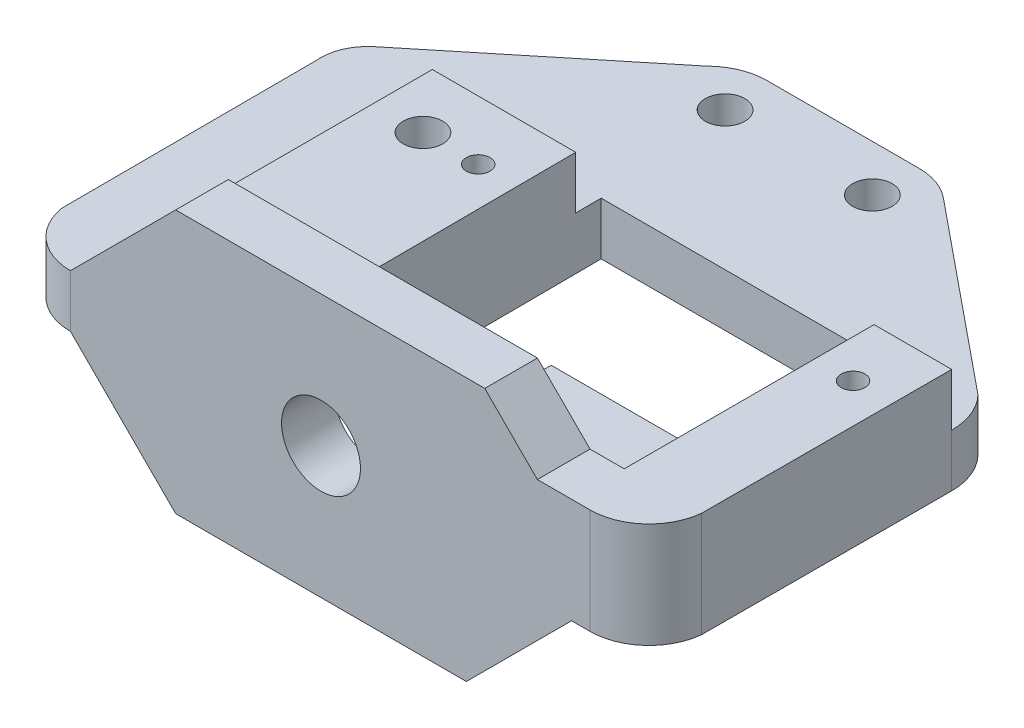
from build123d import *

# Parameters (mm, degrees)
CROQUIS1_R              = 1.500000078
CROQUIS1_R_2            = 0.899999978
CROQUIS1_R_3            = 0.899999104
CROQUIS1_R_4            = 1.499997939
CROQUIS1_R_5            = 1.500000378
SALIENTE_EXTRUIR1_DEPTH = 4
CROQUIS2_R              = 1.500000078
CROQUIS2_R_2            = 0.899999978
CROQUIS2_R_3            = 0.899999104
SALIENTE_EXTRUIR2_DEPTH = 4
CROQUIS3_W              = 35.500002289
CROQUIS3_H              = 4.004000187
SALIENTE_EXTRUIR3_DEPTH = 4
CROQUIS4_W              = 38.100002289
CROQUIS4_H              = 4.004000187
SALIENTE_EXTRUIR4_DEPTH = 8
CROQUIS5_R              = 3
CORTAR_EXTRUIR1_DEPTH   = 8


with BuildPart() as part:
    # Croquis1 → Saliente-Extruir1 (new body)
    with BuildSketch(Plane(origin=(0, 0, 0), x_dir=(1, 0, 0), z_dir=(0, 1, 0))):
        with BuildLine():
            Line((-19.24526482, -19.128405422), (20.25473518, -19.128405422))
            ThreePointArc((20.25473518, -19.128405422), (23.250093999, -17.982284574), (24.715306469, -15.12940535))
            Line((24.715306469, -15.12940535), (24.75473518, 3.871594578))
            ThreePointArc((24.75473518, 3.871594578), (24.41495197, 5.657410091), (23.436719128, 7.189614445))
            Line((23.436719128, 7.189614445), (9.132638286, 18.858517697))
            ThreePointArc((9.132638286, 18.858517697), (7.79788024, 19.61076911), (6.288102337, 19.871598393))
            Line((6.288102337, 19.871598393), (-5.278630069, 19.871598393))
            ThreePointArc((-5.278630069, 19.871598393), (-7.047350485, 19.518737385), (-8.545265011, 18.514180332))
            Line((-8.545265011, 18.514180332), (-22.427247654, 7.189612922))
            ThreePointArc((-22.427247654, 7.189612922), (-23.487263037, 5.764725879), (-23.74526482, 4.007634312))
            Line((-23.74526482, 4.007634312), (-23.68986282, -15.332360357))
            ThreePointArc((-23.68986282, -15.332360357), (-22.167781266, -18.050232235), (-19.24526482, -19.128405422))
        make_face()
        with Locations((-10.945264306, -0.628405976)):
            Circle(CROQUIS1_R, mode=Mode.SUBTRACT)
        with Locations((-6.745264379, -0.628405738)):
            Circle(CROQUIS1_R_2, mode=Mode.SUBTRACT)
        with Locations((21.754736572, -0.628405422)):
            Circle(CROQUIS1_R_3, mode=Mode.SUBTRACT)
        with Locations((6.25473312, 16.341597706)):
            Circle(CROQUIS1_R_4, mode=Mode.SUBTRACT)
        with Locations((-4.945262866, 16.341595261)):
            Circle(CROQUIS1_R_5, mode=Mode.SUBTRACT)
        Polygon((-3.845263294, 5.821595341), (-3.74526482, -15.124405235), (5.25473518, -15.124405235), (5.25473518, -7.078405231), (18.854737469, -7.078405231), (18.854737469, 5.821595341), align=None, mode=Mode.SUBTRACT)
    extrude(amount=SALIENTE_EXTRUIR1_DEPTH)

    # Croquis2 → Saliente-Extruir2 (add)
    with BuildSketch(Plane(origin=(0, 4, 0), x_dir=(1, 0, 0), z_dir=(0, 1, 0))):
        with BuildLine():
            Line((-3.74526482, -15.124405235), (-3.835972877, 3.875594765))
            Line((-3.835972877, 3.875594765), (-14.735972877, 3.875594765))
            Line((-14.735972877, 3.875594765), (-14.735972877, -15.124405235))
            Line((-14.735972877, -15.124405235), (-19.24526482, -15.124405235))
            Line((-19.24526482, -15.124405235), (-19.24526482, -19.128405422))
            Line((-19.24526482, -19.128405422), (20.25473518, -19.128405422))
            ThreePointArc((20.25473518, -19.128405422), (23.250093999, -17.982284574), (24.715306469, -15.12940535))
            Line((24.715306469, -15.12940535), (24.75473518, 3.871594578))
            Line((24.75473518, 3.871594578), (18.854737469, 3.871594578))
            Line((18.854737469, 3.871594578), (18.854737469, -7.078405231))
            Line((18.854737469, -7.078405231), (18.854737469, -15.124405235))
            Line((18.854737469, -15.124405235), (5.25473518, -15.124405235))
            Line((5.25473518, -15.124405235), (-3.74526482, -15.124405235))
        make_face()
        with Locations((-10.945264306, -0.628405976)):
            Circle(CROQUIS2_R, mode=Mode.SUBTRACT)
        with Locations((-6.745264379, -0.628405738)):
            Circle(CROQUIS2_R_2, mode=Mode.SUBTRACT)
        with Locations((21.754736572, -0.628405422)):
            Circle(CROQUIS2_R_3, mode=Mode.SUBTRACT)
    extrude(amount=SALIENTE_EXTRUIR2_DEPTH)

    # Croquis3 → Saliente-Extruir3 (add)
    with BuildSketch(Plane(origin=(0, 8, 0), x_dir=(1, 0, 0), z_dir=(0, 1, 0))):
        with Locations((-1.495263676, -17.126405328)):
            Rectangle(CROQUIS3_W, CROQUIS3_H)
    extrude(amount=SALIENTE_EXTRUIR3_DEPTH)

    # Croquis4 → Saliente-Extruir4 (add)
    with BuildSketch(Plane.XZ):
        with Locations((-0.195263676, 17.126405328)):
            Rectangle(CROQUIS4_W, CROQUIS4_H)
    extrude(amount=SALIENTE_EXTRUIR4_DEPTH)

    # Croquis5 → Cortar-Extruir1 (cut)
    with BuildSketch(Plane.XY.offset(19.128405422)):
        with Locations((-0.195262531, 2)):
            Circle(CROQUIS5_R)
        Polygon((16.254737469, 8), (12.254737469, 12), (16.254737469, 12), align=None)
        Polygon((-19.24526482, 4), (-11.24526482, 12), (-19.24526482, 12), align=None)
        Polygon((-19.24526482, 0), (-11.24526482, -8), (-19.24526482, -8), align=None)
        Polygon((18.854737469, -8), (10.854737469, -8), (18.854737469, 0), align=None)
    extrude(amount=-CORTAR_EXTRUIR1_DEPTH, mode=Mode.SUBTRACT)


solid = part.part
